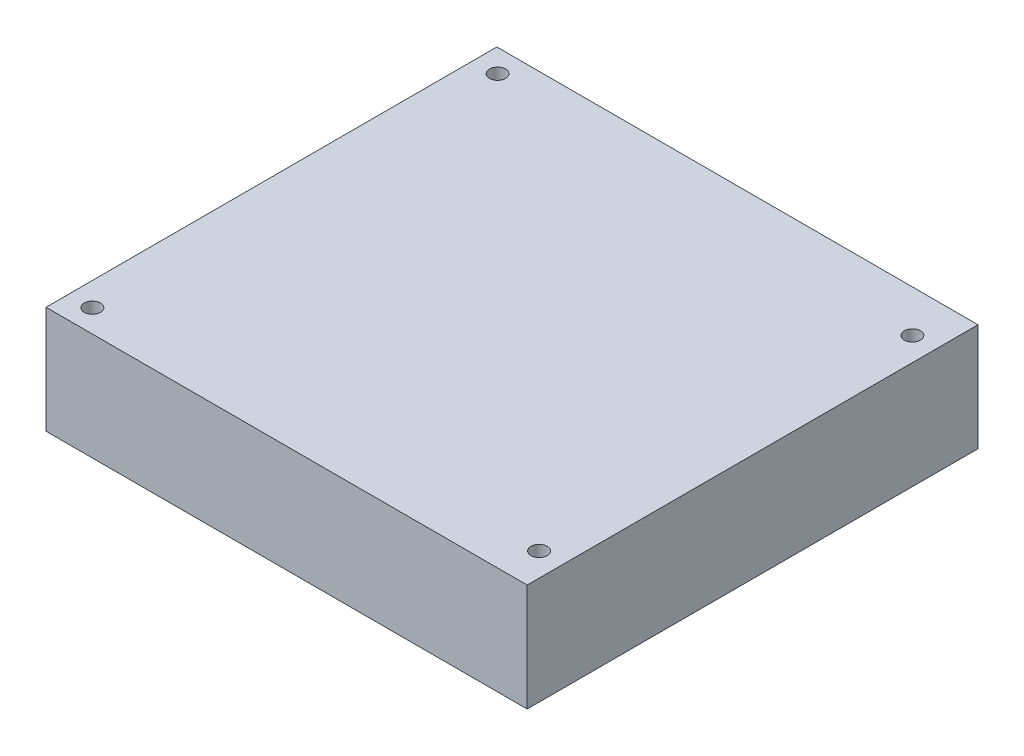
from build123d import *

# Parameters (mm, degrees)
SKETCH1_W           = 95
SKETCH1_H           = 89.01
SKETCH1_R           = 1.6
BOSS_EXTRUDE1_DEPTH = 21.2


with BuildPart() as part:
    # Sketch1 → Boss-Extrude1 (new body)
    with BuildSketch(Plane(origin=(0, 0, 0), x_dir=(1, 0, 0), z_dir=(0, 1, 0))):
        Rectangle(SKETCH1_W, SKETCH1_H)
        with Locations((-42.85, 40)):
            Circle(SKETCH1_R, mode=Mode.SUBTRACT)
        with Locations((42.85, 36.2)):
            Circle(SKETCH1_R, mode=Mode.SUBTRACT)
        with Locations((-42.85, -40)):
            Circle(SKETCH1_R, mode=Mode.SUBTRACT)
        with Locations((42.85, -37.5)):
            Circle(SKETCH1_R, mode=Mode.SUBTRACT)
    extrude(amount=BOSS_EXTRUDE1_DEPTH)


solid = part.part
